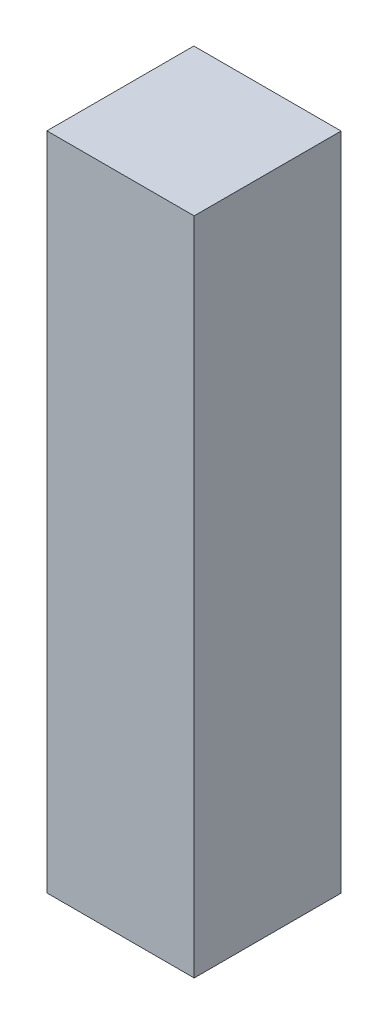
from build123d import *

# Parameters (mm, degrees)
SKETCH2_W           = 204.012463483
SKETCH2_H           = 203.54756047
BOSS_EXTRUDE1_DEPTH = 914.4


with BuildPart() as part:
    # Sketch2 → Boss-Extrude1 (new body)
    with BuildSketch(Plane(origin=(0, 0, 0), x_dir=(1, 0, 0), z_dir=(0, 1, 0))):
        with Locations((121.197342853, -84.036541178)):
            Rectangle(SKETCH2_W, SKETCH2_H)
    extrude(amount=-BOSS_EXTRUDE1_DEPTH)


solid = part.part
